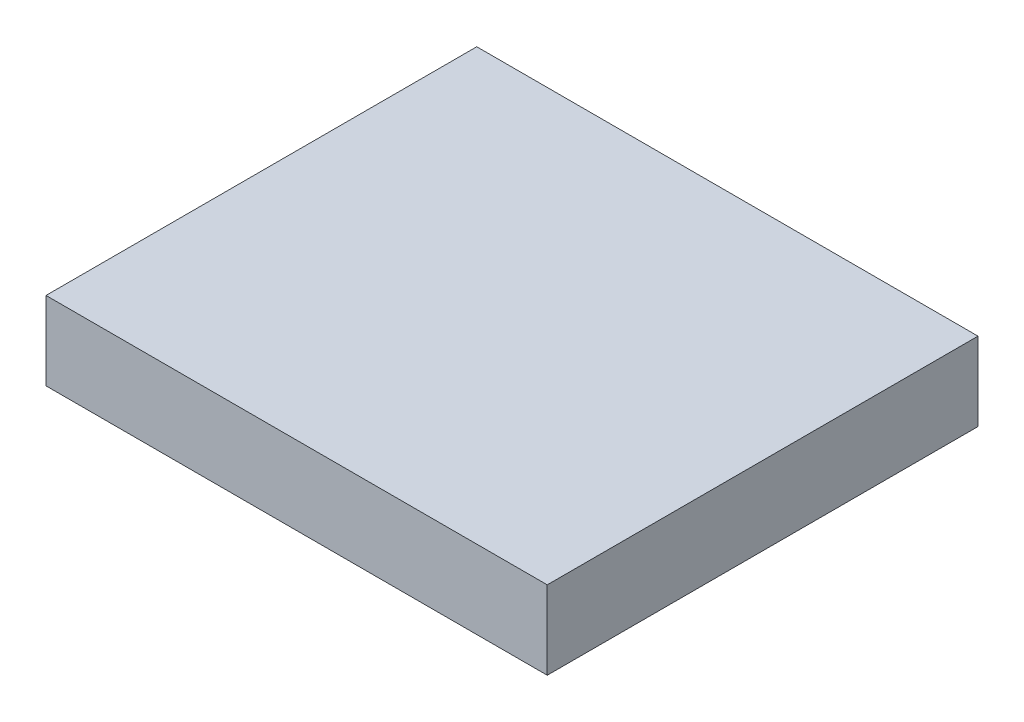
from build123d import *

# Parameters (mm, degrees)
SKETCH1_W           = 812.8
SKETCH1_H           = 698.5
BOSS_EXTRUDE1_DEPTH = 127


with BuildPart() as part:
    # Sketch1 → Boss-Extrude1 (new body)
    with BuildSketch(Plane(origin=(0, 0, 0), x_dir=(1, 0, 0), z_dir=(0, 1, 0))):
        Rectangle(SKETCH1_W, SKETCH1_H)
    extrude(amount=BOSS_EXTRUDE1_DEPTH)


solid = part.part
